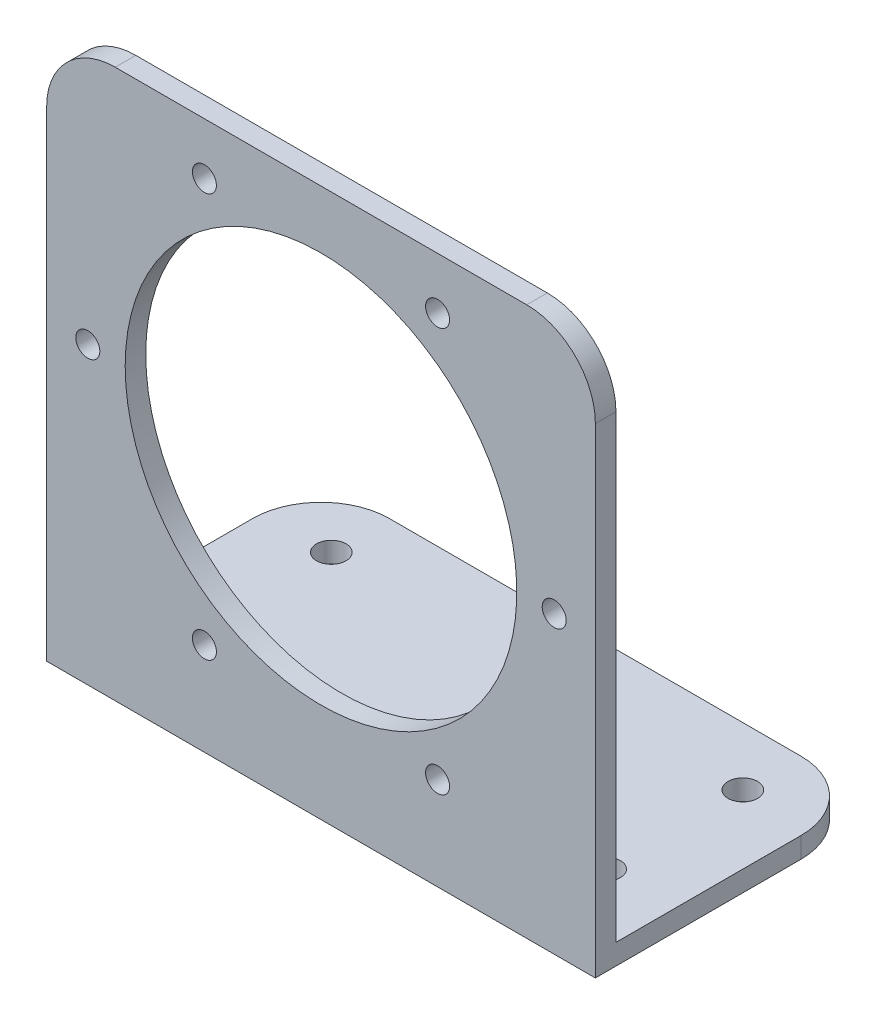
from build123d import *

# Parameters (mm, degrees)
EXTRUDE_1_DEPTH        = 40
SKETCH_3_R             = 1.75
SKETCH_3_R_2           = 28.55
MOTOR_FIXED_HOLE_DEPTH = 4
SKETCH_4_R             = 2.15
BASE_HOLE_DEPTH        = 4
FILLET_1_R             = 10


with BuildPart() as part:
    # 草圖2 → 填料-伸長1 (new body, symmetric)
    with BuildSketch(Plane(origin=(0, 0, 0), x_dir=(0, 0, -1), z_dir=(1, 0, 0))):
        Polygon((0, 80), (0, 0), (40, 0), (40, 3), (3, 3), (3, 80), align=None)
    extrude(amount=EXTRUDE_1_DEPTH, both=True)

    # 草圖3 → motor_fixed_hole (cut, through all)
    with BuildSketch(Plane(origin=(0, 0, -3), x_dir=(-1, 0, 0), z_dir=(0, 0, -1))):
        with Locations((17, 72.444863729)):
            Circle(SKETCH_3_R)
        with Locations((34, 43)):
            Circle(SKETCH_3_R)
        with Locations((17, 13.555136271)):
            Circle(SKETCH_3_R)
        with Locations((-17, 13.555136271)):
            Circle(SKETCH_3_R)
        with Locations((-34, 43)):
            Circle(SKETCH_3_R)
        with Locations((-17, 72.444863729)):
            Circle(SKETCH_3_R)
        with Locations((0, 43)):
            Circle(SKETCH_3_R_2)
    extrude(amount=-MOTOR_FIXED_HOLE_DEPTH, mode=Mode.SUBTRACT)

    # 草圖4 → base_hole (cut, through all)
    with BuildSketch(Plane(origin=(0, 3, 0), x_dir=(1, 0, 0), z_dir=(0, 1, 0))):
        with Locations((-30, 31.5)):
            Circle(SKETCH_4_R)
        with Locations((-30, 11.5)):
            Circle(SKETCH_4_R)
        with Locations((30, 11.5)):
            Circle(SKETCH_4_R)
        with Locations((30, 31.5)):
            Circle(SKETCH_4_R)
    extrude(amount=-BASE_HOLE_DEPTH, mode=Mode.SUBTRACT)

    # 圓角1
    fillet_1_edges = [part.edges().sort_by_distance(p)[0] for p in [
        (40, 1.5, -40),
        (40, 80, -1.5),
        (-40, 80, -1.5),
        (-40, 1.5, -40),
    ]]
    fillet(fillet_1_edges, radius=FILLET_1_R)


solid = part.part
